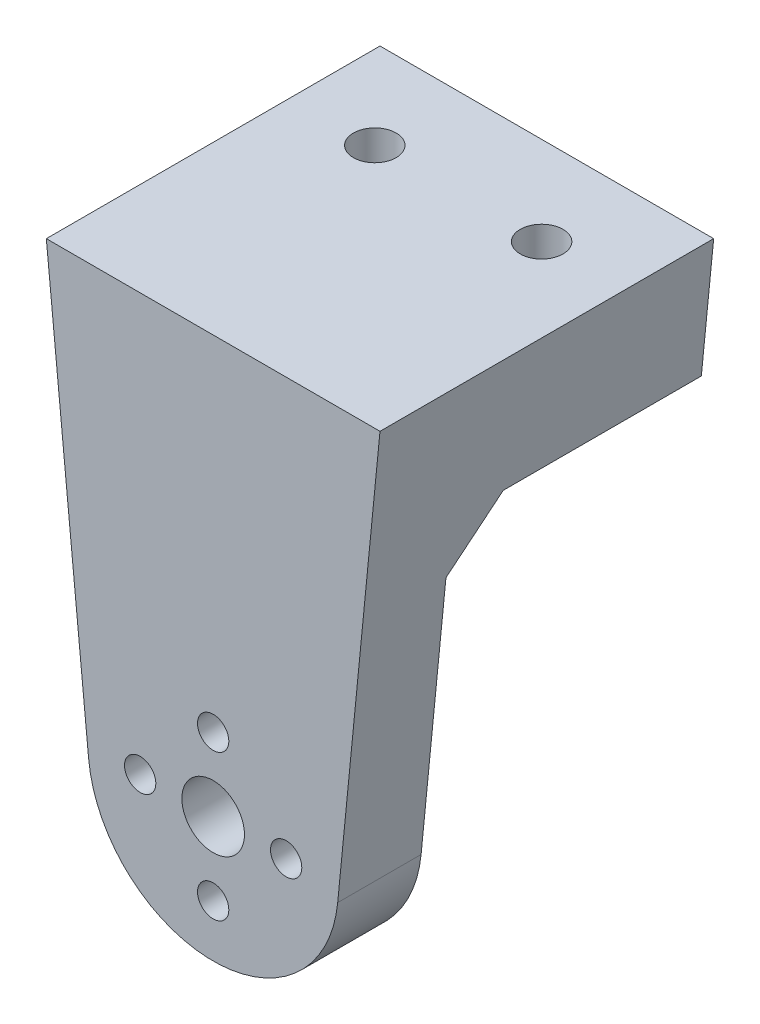
from build123d import *

# Parameters (mm, degrees)
SKETCH1_R           = 1.5
BOSS_EXTRUDE1_DEPTH = 8
BOSS_EXTRUDE2_DEPTH = 24
CHAMFER1_SIZE       = 5
CUT_EXTRUDE2_REACH  = 10
SKETCH5_R           = 3
SKETCH6_R           = 2.05
CUT_EXTRUDE6_DEPTH  = 5


with BuildPart() as part:
    # Sketch1 → Boss-Extrude1 (new body)
    with BuildSketch(Plane.XY):
        with BuildLine():
            Line((-16, 40), (-11.942152172, -1.176860869))
            ThreePointArc((-11.942152172, -1.176860869), (0, -12), (11.942152172, -1.176860869))
            Line((11.942152172, -1.176860869), (16, 40))
            Line((16, 40), (-16, 40))
        make_face()
        with Locations((7, 0)):
            Circle(SKETCH1_R, mode=Mode.SUBTRACT)
        with Locations((0, 7)):
            Circle(SKETCH1_R, mode=Mode.SUBTRACT)
        with Locations((0, -7)):
            Circle(SKETCH1_R, mode=Mode.SUBTRACT)
        with Locations((-7, 0)):
            Circle(SKETCH1_R, mode=Mode.SUBTRACT)
    extrude(amount=BOSS_EXTRUDE1_DEPTH)

    # Sketch3 → Boss-Extrude2 (add)
    with BuildSketch(Plane(origin=(0, 0, 0), x_dir=(-1, 0, 0), z_dir=(0, 0, -1))):
        Polygon((14.817438413, 28), (-14.817438413, 28), (-16, 40), (16, 40), align=None)
    extrude(amount=BOSS_EXTRUDE2_DEPTH)

    # Chamfer1
    chamfer1_edges = [part.edges().sort_by_distance(p)[0] for p in [
        (0, 28, 0),
    ]]
    chamfer(chamfer1_edges, length=CHAMFER1_SIZE)

    # Sketch5 → Cut-Extrude2 (cut, up to next)
    with BuildSketch(Plane(origin=(0, 0, 0), x_dir=(-1, 0, 0), z_dir=(0, 0, -1)), mode=Mode.PRIVATE) as cut_extrude2_sk1:
        Circle(SKETCH5_R)
    cut_extrude2_tool1 = extrude(cut_extrude2_sk1.sketch, amount=-CUT_EXTRUDE2_REACH, mode=Mode.PRIVATE) & part.part
    add(cut_extrude2_tool1.solids().sort_by_distance((0, 0, 0))[0], mode=Mode.SUBTRACT)

    # Sketch6 → Cut-Extrude6 (cut)
    with BuildSketch(Plane.XZ.offset(-40)):
        with Locations((-8, -15.5)):
            Circle(SKETCH6_R)
        with Locations((8, -15.5)):
            Circle(SKETCH6_R)
    extrude(amount=CUT_EXTRUDE6_DEPTH, mode=Mode.SUBTRACT)


solid = part.part
